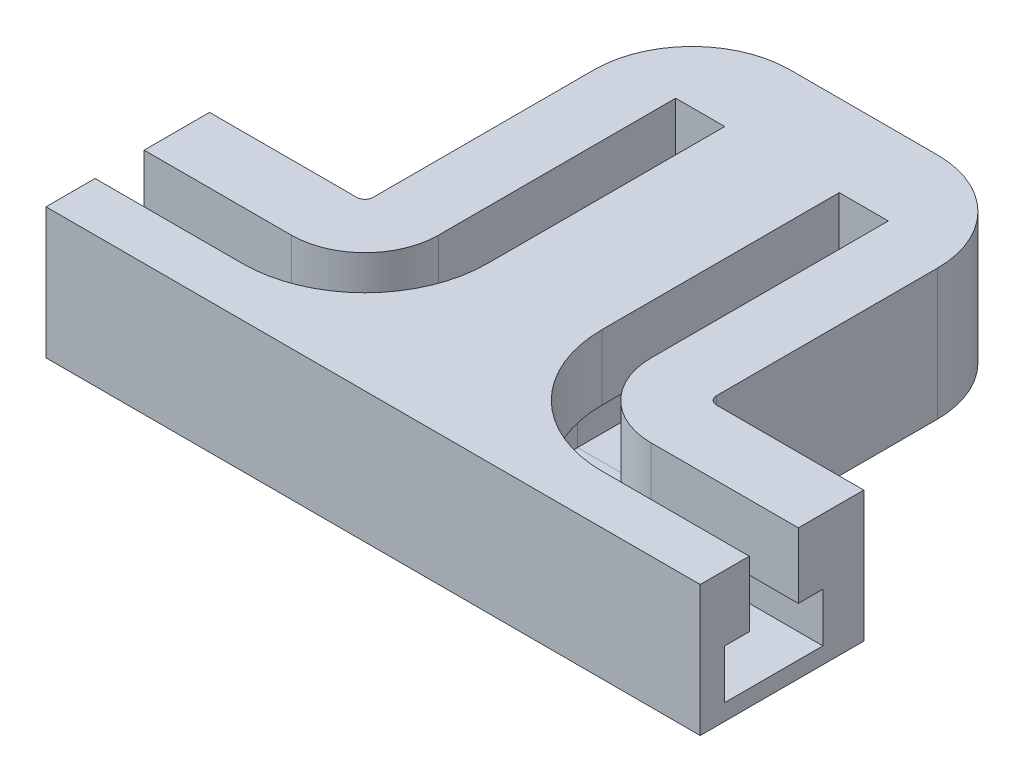
from build123d import *

# Parameters (mm, degrees)
SKETCH1_W            = 100
SKETCH1_H            = 40
BOSS_EXTRUDE1_DEPTH  = 150
CUT_EXTRUDE1_DEPTH   = 41
FILLET1_R            = 30
FILLET1_OF_MIRROR1_R = 30


with BuildPart() as part:
    # Sketch1 → Boss-Extrude1 (new body)
    with BuildSketch(Plane.XY):
        with Locations((-50, 20)):
            Rectangle(SKETCH1_W, SKETCH1_H)
    boss_extrude1 = extrude(amount=BOSS_EXTRUDE1_DEPTH)

    # Cut-Sweep1: sweep along a path in Sketch3
    with BuildLine(Plane(origin=(0, 40, 0), x_dir=(1, 0, 0), z_dir=(0, 1, 0))) as cut_sweep1_path:
        Line((-100, -127.5), (-55, -127.5))
        ThreePointArc((-55, -127.5), (-33.786796564, -118.713203436), (-25, -97.5))
        Line((-25, -97.5), (-25, -25))
    # Sketch2 → Cut-Sweep1 (sweep, cut)
    with BuildSketch(Plane.ZY.offset(100)):
        Polygon((135, 40), (120, 40), (120, 20), (112.5, 20), (112.5, 5), (142.5, 5), (142.5, 20), (135, 20), align=None)
    cut_sweep1 = sweep(path=cut_sweep1_path.line, mode=Mode.SUBTRACT)

    # Sketch4 → Cut-Extrude1 (cut, through all)
    with BuildSketch(Plane(origin=(0, 40, 0), x_dir=(1, 0, 0), z_dir=(0, 1, 0))):
        with BuildLine():
            Line((-52.5, -25), (-52.5, 0))
            Line((-52.5, 0), (-100, 0))
            Line((-100, 0), (-100, -100))
            Line((-100, -100), (-55, -100))
            ThreePointArc((-55, -100), (-53.232233047, -99.267766953), (-52.5, -97.5))
            Line((-52.5, -97.5), (-52.5, -25))
        make_face()
    cut_extrude1 = extrude(amount=-CUT_EXTRUDE1_DEPTH, mode=Mode.SUBTRACT)

    # Fillet1
    fillet1_edges = [part.edges().sort_by_distance(p)[0] for p in [
        (-52.5, 20, 0),
    ]]
    fillet(fillet1_edges, radius=FILLET1_R)

    # Mirror1: Boss-Extrude1, Cut-Sweep1, Cut-Extrude1 across plane
    add(boss_extrude1.mirror(Plane(origin=(0, 0, 150), x_dir=(0, 0, 1), z_dir=(-1, 0, 0))))
    add(cut_sweep1.mirror(Plane(origin=(0, 0, 150), x_dir=(0, 0, 1), z_dir=(-1, 0, 0))), mode=Mode.SUBTRACT)
    add(cut_extrude1.mirror(Plane(origin=(0, 0, 150), x_dir=(0, 0, 1), z_dir=(-1, 0, 0))), mode=Mode.SUBTRACT)

    # Fillet1 of Mirror1
    fillet1_of_mirror1_edges = [part.edges().sort_by_distance(p)[0] for p in [
        (52.5, 20, 0),
    ]]
    fillet(fillet1_of_mirror1_edges, radius=FILLET1_OF_MIRROR1_R)


solid = part.part
